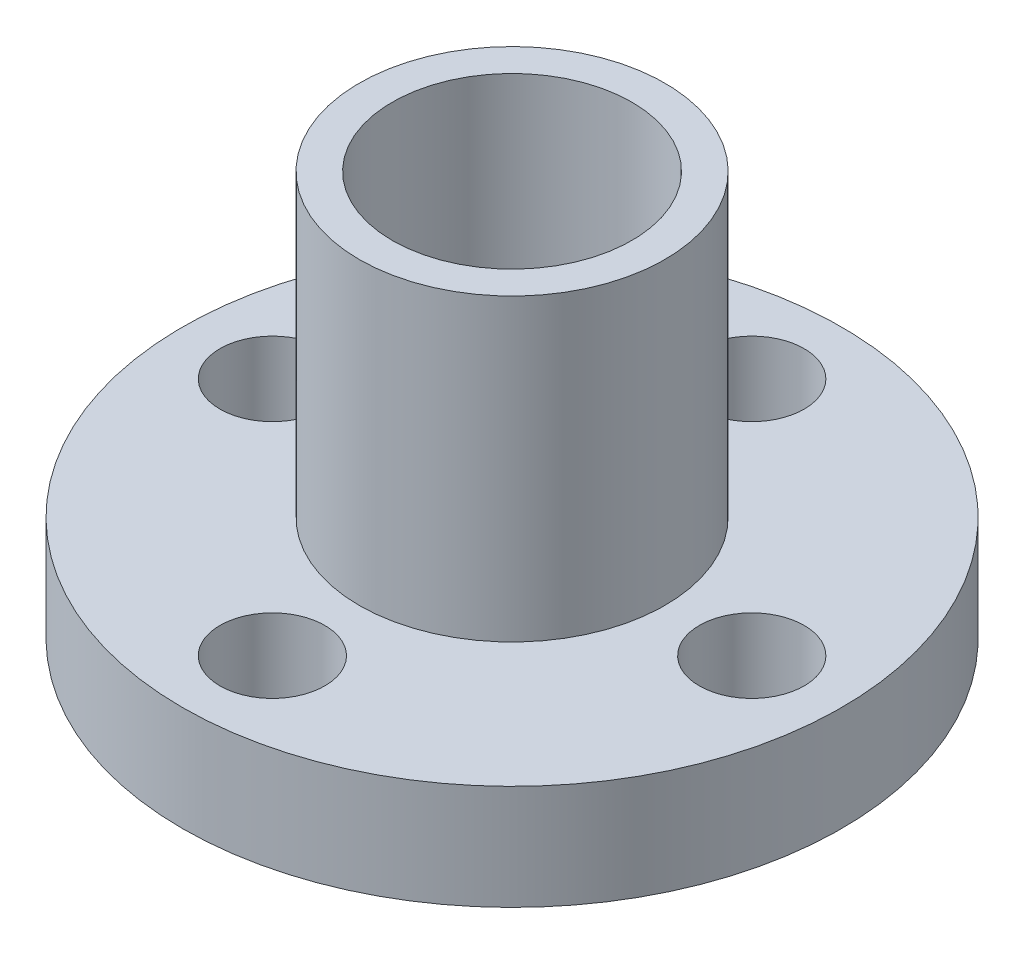
from build123d import *

# Parameters (mm, degrees)
SKETCH1_R           = 5.1
BOSS_EXTRUDE1_DEPTH = 1.5
SKETCH2_R           = 11
BOSS_EXTRUDE2_DEPTH = 3.5
SKETCH3_R           = 5.1
BOSS_EXTRUDE3_DEPTH = 10
SKETCH4_R           = 4
SKETCH4_R_2         = 1.75
CUT_EXTRUDE1_DEPTH  = 16


with BuildPart() as part:
    # Sketch1 → Boss-Extrude1 (new body)
    with BuildSketch(Plane(origin=(0, 0, 0), x_dir=(1, 0, 0), z_dir=(0, 1, 0))):
        Circle(SKETCH1_R)
    extrude(amount=BOSS_EXTRUDE1_DEPTH)

    # Sketch2 → Boss-Extrude2 (add)
    with BuildSketch(Plane(origin=(0, 1.5, 0), x_dir=(1, 0, 0), z_dir=(0, 1, 0))):
        Circle(SKETCH2_R)
    extrude(amount=BOSS_EXTRUDE2_DEPTH)

    # Sketch3 → Boss-Extrude3 (add)
    with BuildSketch(Plane(origin=(0, 5, 0), x_dir=(1, 0, 0), z_dir=(0, 1, 0))):
        Circle(SKETCH3_R)
    extrude(amount=BOSS_EXTRUDE3_DEPTH)

    # Sketch4 → Cut-Extrude1 (cut, through all)
    with BuildSketch(Plane(origin=(0, 15, 0), x_dir=(1, 0, 0), z_dir=(0, 1, 0))):
        Circle(SKETCH4_R)
        with Locations((8, 0)):
            Circle(SKETCH4_R_2)
        with Locations((0, 8)):
            Circle(SKETCH4_R_2)
        with Locations((-8, 0)):
            Circle(SKETCH4_R_2)
        with Locations((0, -8)):
            Circle(SKETCH4_R_2)
    extrude(amount=-CUT_EXTRUDE1_DEPTH, mode=Mode.SUBTRACT)


solid = part.part
